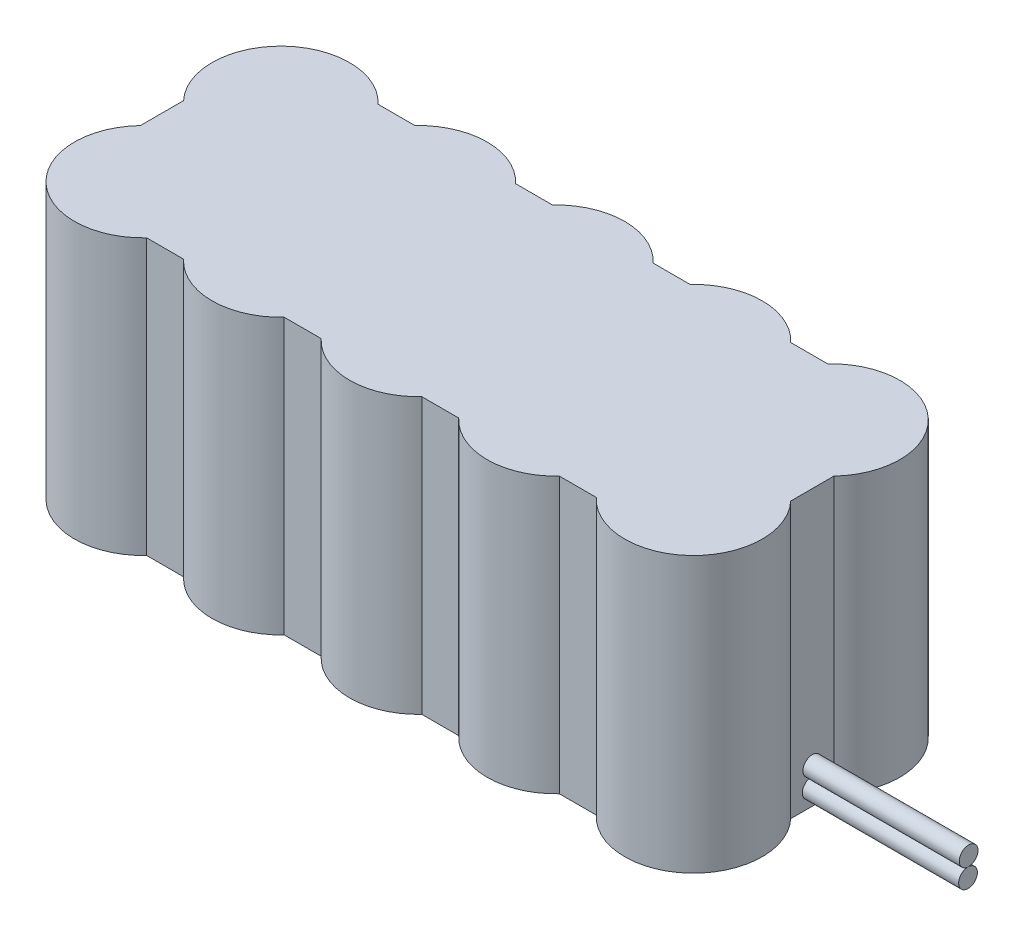
from build123d import *

# Parameters (mm, degrees)
SKETCH1_R         = 11
EXTRUDE1_DEPTH    = 44
EXTRUDE1_2_DEPTH  = 44
EXTRUDE1_3_DEPTH  = 44
EXTRUDE1_4_DEPTH  = 44
EXTRUDE1_5_DEPTH  = 44
EXTRUDE1_6_DEPTH  = 44
EXTRUDE1_7_DEPTH  = 44
EXTRUDE1_8_DEPTH  = 44
EXTRUDE1_9_DEPTH  = 44
EXTRUDE1_10_DEPTH = 44
SKETCH2_W         = 104
SKETCH2_H         = 37
EXTRUDE7_DEPTH    = 44
SKETCH4_R         = 1.5
EXTRUDE12_DEPTH   = 25
SKETCH5_R         = 1.5
EXTRUDE14_DEPTH   = 25


with BuildPart() as part:
    # Sketch1 → Extrude1 (new body)
    with BuildSketch(Plane(origin=(0, 0, 0), x_dir=(1, 0, 0), z_dir=(0, 1, 0))):
        Circle(SKETCH1_R)
    extrude(amount=EXTRUDE1_DEPTH)



with BuildPart() as body_2:
    # Sketch1 → Extrude1 2 (new body)
    with BuildSketch(Plane(origin=(0, 0, 0), x_dir=(1, 0, 0), z_dir=(0, 1, 0))):
        with Locations((22, 0)):
            Circle(SKETCH1_R)
    extrude(amount=EXTRUDE1_2_DEPTH)


with BuildPart() as body_3:
    # Sketch1 → Extrude1 3 (new body)
    with BuildSketch(Plane(origin=(0, 0, 0), x_dir=(1, 0, 0), z_dir=(0, 1, 0))):
        with Locations((44, 0)):
            Circle(SKETCH1_R)
    extrude(amount=EXTRUDE1_3_DEPTH)


with BuildPart() as body_4:
    # Sketch1 → Extrude1 4 (new body)
    with BuildSketch(Plane(origin=(0, 0, 0), x_dir=(1, 0, 0), z_dir=(0, 1, 0))):
        with Locations((66, 0)):
            Circle(SKETCH1_R)
    extrude(amount=EXTRUDE1_4_DEPTH)


with BuildPart() as body_5:
    # Sketch1 → Extrude1 5 (new body)
    with BuildSketch(Plane(origin=(0, 0, 0), x_dir=(1, 0, 0), z_dir=(0, 1, 0))):
        with Locations((88, 0)):
            Circle(SKETCH1_R)
    extrude(amount=EXTRUDE1_5_DEPTH)


with BuildPart() as body_6:
    # Sketch1 → Extrude1 6 (new body)
    with BuildSketch(Plane(origin=(0, 0, 0), x_dir=(1, 0, 0), z_dir=(0, 1, 0))):
        with Locations((0, 22)):
            Circle(SKETCH1_R)
    extrude(amount=EXTRUDE1_6_DEPTH)


with BuildPart() as body_7:
    # Sketch1 → Extrude1 7 (new body)
    with BuildSketch(Plane(origin=(0, 0, 0), x_dir=(1, 0, 0), z_dir=(0, 1, 0))):
        with Locations((22, 22)):
            Circle(SKETCH1_R)
    extrude(amount=EXTRUDE1_7_DEPTH)


with BuildPart() as body_8:
    # Sketch1 → Extrude1 8 (new body)
    with BuildSketch(Plane(origin=(0, 0, 0), x_dir=(1, 0, 0), z_dir=(0, 1, 0))):
        with Locations((44, 22)):
            Circle(SKETCH1_R)
    extrude(amount=EXTRUDE1_8_DEPTH)


with BuildPart() as body_9:
    # Sketch1 → Extrude1 9 (new body)
    with BuildSketch(Plane(origin=(0, 0, 0), x_dir=(1, 0, 0), z_dir=(0, 1, 0))):
        with Locations((66, 22)):
            Circle(SKETCH1_R)
    extrude(amount=EXTRUDE1_9_DEPTH)


with BuildPart() as body_10:
    # Sketch1 → Extrude1 10 (new body)
    with BuildSketch(Plane(origin=(0, 0, 0), x_dir=(1, 0, 0), z_dir=(0, 1, 0))):
        with Locations((88, 22)):
            Circle(SKETCH1_R)
    extrude(amount=EXTRUDE1_10_DEPTH)


with BuildPart() as part_1:
    add(part.part)

    add(body_2.part)  # Extrude7 merges body 2

    add(body_3.part)  # Extrude7 merges body 3

    add(body_4.part)  # Extrude7 merges body 4

    add(body_5.part)  # Extrude7 merges body 5

    add(body_6.part)  # Extrude7 merges body 6

    add(body_7.part)  # Extrude7 merges body 7

    add(body_8.part)  # Extrude7 merges body 8

    add(body_9.part)  # Extrude7 merges body 9

    add(body_10.part)  # Extrude7 merges body 10
    # Sketch2 → Extrude7 (add)
    with BuildSketch(Plane(origin=(0, 44, 0), x_dir=(1, 0, 0), z_dir=(0, 1, 0))):
        with Locations((44, 11)):
            Rectangle(SKETCH2_W, SKETCH2_H)
    extrude(amount=-EXTRUDE7_DEPTH)

    # Sketch4 → Extrude12 (add)
    with BuildSketch(Plane(origin=(96, 0, 0), x_dir=(0, 0, -1), z_dir=(1, 0, 0))):
        with Locations((11, 5.639322164)):
            Circle(SKETCH4_R)
    extrude(amount=EXTRUDE12_DEPTH)


with BuildPart() as body_2_2:
    # Sketch5 → Extrude14 (new body)
    with BuildSketch(Plane(origin=(96, 0, 0), x_dir=(0, 0, -1), z_dir=(1, 0, 0))):
        with Locations((10.904759515, 2.639322164)):
            Circle(SKETCH5_R)
    extrude(amount=EXTRUDE14_DEPTH)


solid = Compound([part_1.part, body_2_2.part])
